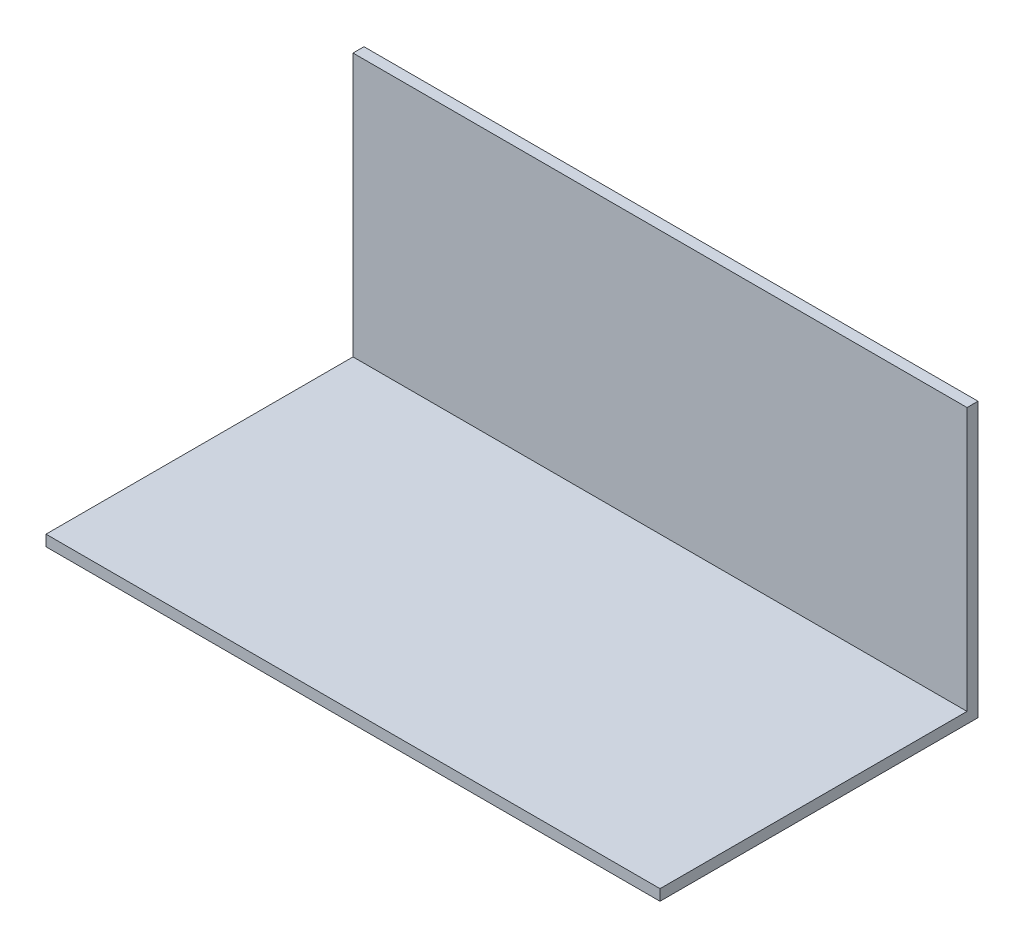
from build123d import *

# Parameters (mm, degrees)
SKETCH1_W           = 355.6
SKETCH1_H           = 184.15
BOSS_EXTRUDE1_DEPTH = 6.35
SKETCH2_W           = 355.6
SKETCH2_H           = 6.35
BOSS_EXTRUDE2_DEPTH = 152.4


with BuildPart() as part:
    # Sketch1 → Boss-Extrude1 (new body)
    with BuildSketch(Plane(origin=(0, 0, 0), x_dir=(1, 0, 0), z_dir=(0, 1, 0))):
        with Locations((177.8, 92.075)):
            Rectangle(SKETCH1_W, SKETCH1_H)
    extrude(amount=BOSS_EXTRUDE1_DEPTH)

    # Sketch2 → Boss-Extrude2 (add)
    with BuildSketch(Plane(origin=(0, 6.35, 0), x_dir=(1, 0, 0), z_dir=(0, 1, 0))):
        with Locations((177.8, 180.975)):
            Rectangle(SKETCH2_W, SKETCH2_H)
    extrude(amount=BOSS_EXTRUDE2_DEPTH)


solid = part.part
